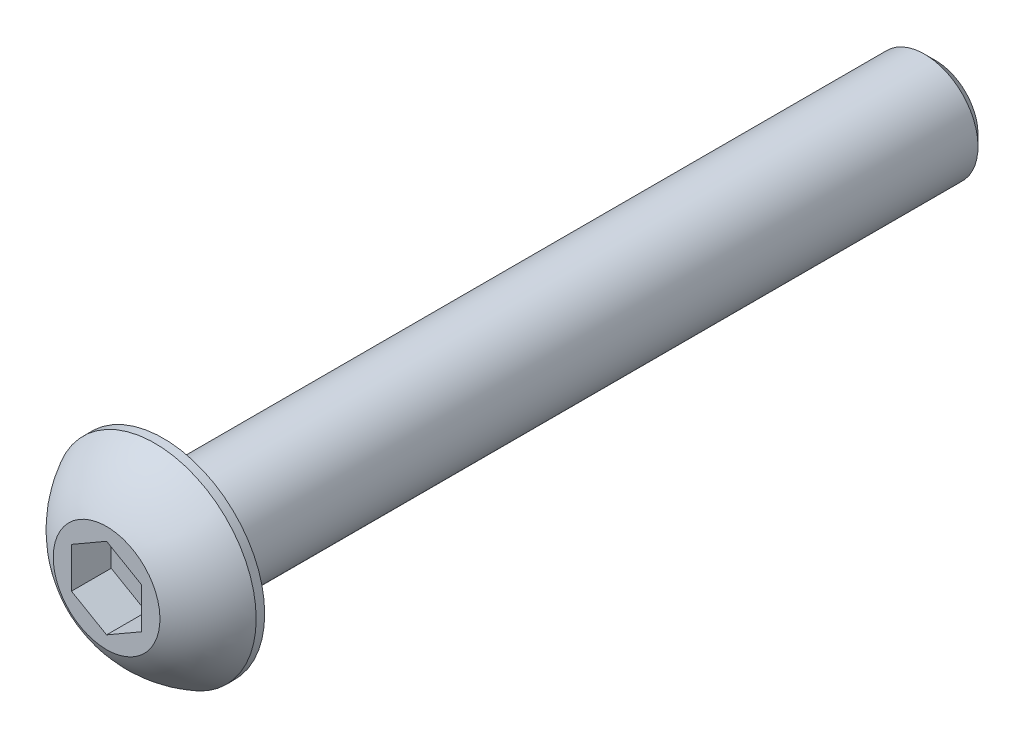
from build123d import *

# Parameters (mm, degrees)
SKETCH11_W         = 34.925
SKETCH11_H         = 2.413
CHAMFER1_SIZE      = 0.49609375
CUT_EXTRUDE2_DEPTH = 1.79578


with BuildPart() as part:
    # Sketch11 → Revolve1 (revolve)
    with BuildSketch(Plane(origin=(0, 0, 0), x_dir=(0, 0, -1), z_dir=(1, 0, 0)), mode=Mode.PRIVATE) as revolve1_sk:
        with Locations((20.0279, 1.2065)):
            Rectangle(SKETCH11_W, SKETCH11_H)
    revolve(revolve1_sk.sketch.rotate(Axis((0, 0, -2.5654), (0, 0, -1)), 180), axis=Axis((0, 0, -2.5654), (0, 0, -1)))

    # Chamfer1
    chamfer1_edges = [part.edges().sort_by_distance(p)[0] for p in [
        (0, 2.413, -37.4904),
    ]]
    chamfer(chamfer1_edges, length=CHAMFER1_SIZE)


with BuildPart() as body_2:
    # Sketch7 → Revolve2 (revolve)
    with BuildSketch(Plane(origin=(0, 0, 0), x_dir=(0, 0, -1), z_dir=(1, 0, 0)), mode=Mode.PRIVATE) as revolve2_sk:
        with BuildLine():
            Line((2.18059, 4.5847), (2.5654, 4.5847))
            Line((2.5654, 4.5847), (2.5654, 0))
            Line((2.5654, 0), (0, 0))
            Line((0, 0), (0, 2.413))
            ThreePointArc((0, 2.413), (0.925030326, 3.664791196), (2.18059, 4.5847))
        make_face()
    revolve(revolve2_sk.sketch.rotate(Axis((0, 0, 0), (0, 0, -1)), 180), axis=Axis((0, 0, 0), (0, 0, -1)))

    # Sketch5 → Cut-Extrude2 (cut)
    with BuildSketch(Plane.XY):
        Polygon((1.5875, -0.916543552), (1.5875, 0.916543552), (0, 1.833087105), (-1.5875, 0.916543552), (-1.5875, -0.916543552), (0, -1.833087105), align=None)
    extrude(amount=-CUT_EXTRUDE2_DEPTH, mode=Mode.SUBTRACT)


solid = Compound([part.part, body_2.part])
